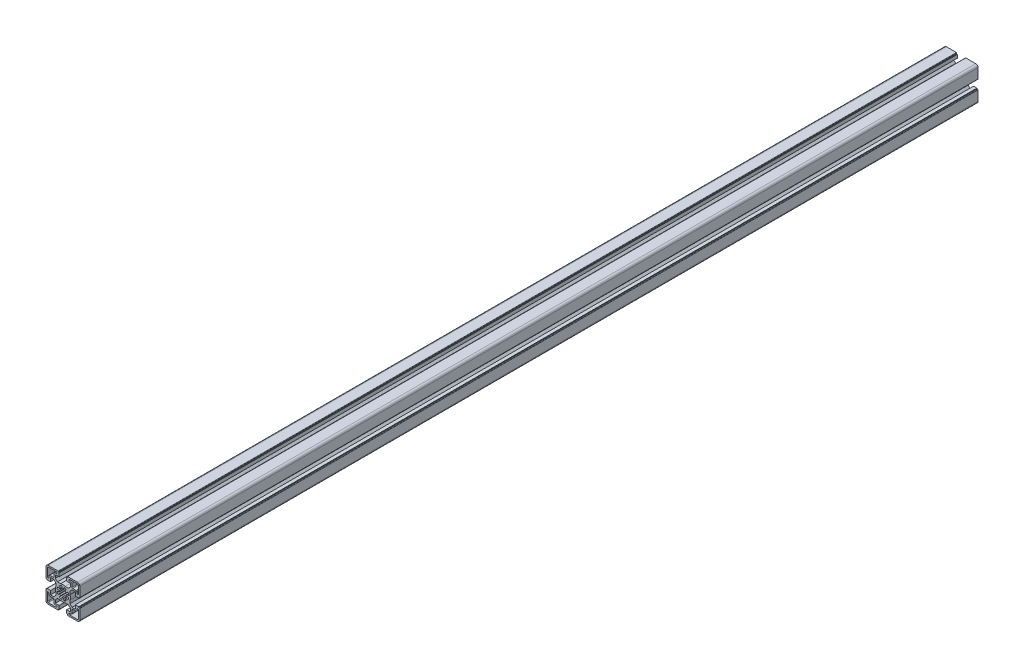
from build123d import *

# Parameters (mm, degrees)
BASE_EXTRUDE_DEPTH = 1196


with BuildPart() as part:
    # Sketch1 → Base-Extrude (new body)
    with BuildSketch(Plane.XY):
        with BuildLine():
            Line((-4.99999574, -16.499883971), (-4.99999574, -20.99990968))
            Line((-4.99999574, -20.99990968), (-5.80004044, -20.99990968))
            Line((-5.80004044, -20.99990968), (-5.80004044, -21.999970054))
            ThreePointArc((-5.80004044, -21.999970054), (-5.946487232, -22.353523887), (-6.300041066, -22.49997068))
            Line((-6.300041066, -22.49997068), (-19.500014911, -22.49997068))
            ThreePointArc((-19.500014911, -22.49997068), (-21.62133367, -21.62129168), (-22.50001267, -19.499972921))
            Line((-22.50001267, -19.499972921), (-22.50001267, -6.299929564))
            ThreePointArc((-22.50001267, -6.299929564), (-22.353566213, -5.946376541), (-22.00001319, -5.799930084))
            Line((-22.00001319, -5.799930084), (-21.000012806, -5.799930084))
            Line((-21.000012806, -5.799930084), (-21.000012806, -4.999940084))
            Line((-21.000012806, -4.999940084), (-16.500012806, -4.999940084))
            Line((-16.500012806, -4.999940084), (-16.500012806, -10.049940084))
            Line((-16.500012806, -10.049940084), (-12.342923806, -10.049940084))
            Line((-12.342923806, -10.049940084), (-9.499953806, -7.206970084))
            Line((-9.499953806, -7.206970084), (-9.499953806, -3.122617084))
            ThreePointArc((-9.499953806, -3.122617084), (-10.000013376, 6.1916e-05), (-9.499953806, 3.122740916))
            Line((-9.499953806, 3.122740916), (-9.499953806, 7.206970084))
            Line((-9.499953806, 7.206970084), (-12.342923806, 10.049940084))
            Line((-12.342923806, 10.049940084), (-16.500012806, 10.049940084))
            Line((-16.500012806, 10.049940084), (-16.500012806, 4.999940084))
            Line((-16.500012806, 4.999940084), (-21.000012806, 4.999940084))
            Line((-21.000012806, 4.999940084), (-21.000012806, 5.799930084))
            Line((-21.000012806, 5.799930084), (-22.00001319, 5.799930084))
            ThreePointArc((-22.00001319, 5.799930084), (-22.353566213, 5.946376541), (-22.50001267, 6.299929564))
            Line((-22.50001267, 6.299929564), (-22.50001267, 19.499972921))
            ThreePointArc((-22.50001267, 19.499972921), (-21.62133367, 21.62129168), (-19.500014911, 22.49997068))
            Line((-19.500014911, 22.49997068), (-6.299954884, 22.49997068))
            ThreePointArc((-6.299954884, 22.49997068), (-5.946364566, 22.353508775), (-5.799902661, 21.999918456))
            Line((-5.799902661, 21.999918456), (-5.799902661, 20.999918083))
            Line((-5.799902661, 20.999918083), (-4.99999574, 20.999918083))
            Line((-4.99999574, 20.999918083), (-4.99999574, 16.499989166))
            Line((-4.99999574, 16.499989166), (-10.050086009, 16.499989166))
            Line((-10.050086009, 16.499989166), (-10.050086009, 12.342794971))
            Line((-10.050086009, 12.342794971), (-7.207151696, 9.499860659))
            Line((-7.207151696, 9.499860659), (-3.122798696, 9.499860659))
            ThreePointArc((-3.122798696, 9.499860659), (-0.000120196, 9.999920064), (3.122558304, 9.499860659))
            Line((3.122558304, 9.499860659), (7.206958901, 9.499860659))
            Line((7.206958901, 9.499860659), (10.049884116, 12.342787874))
            Line((10.049884116, 12.342787874), (10.049884116, 16.499989166))
            Line((10.049884116, 16.499989166), (4.99999574, 16.499989166))
            Line((4.99999574, 16.499989166), (4.99999574, 20.999963909))
            Line((4.99999574, 20.999963909), (5.799902661, 20.999963909))
            Line((5.799902661, 20.999963909), (5.799902661, 21.999918456))
            ThreePointArc((5.799902661, 21.999918456), (5.946364566, 22.353508775), (6.299954884, 22.49997068))
            Line((6.299954884, 22.49997068), (19.500081571, 22.49997068))
            ThreePointArc((19.500081571, 22.49997068), (21.62140033, 21.62129168), (22.50007933, 19.499972921))
            Line((22.50007933, 19.499972921), (22.50007933, 6.299877709))
            ThreePointArc((22.50007933, 6.299877709), (22.35363283, 5.946324583), (22.000079704, 5.799878083))
            Line((22.000079704, 5.799878083), (20.999995421, 5.799878083))
            Line((20.999995421, 5.799878083), (20.999995421, 4.999941084))
            Line((20.999995421, 4.999941084), (16.499983596, 4.999941084))
            Line((16.499983596, 4.999941084), (16.499983596, 10.049940084))
            Line((16.499983596, 10.049940084), (12.342894596, 10.049940084))
            Line((12.342894596, 10.049940084), (9.499922596, 7.206970084))
            Line((9.499922596, 7.206970084), (9.499922596, 3.122735916))
            ThreePointArc((9.499922596, 3.122735916), (9.999982165, 5.6916e-05), (9.499922596, -3.122622084))
            Line((9.499922596, -3.122622084), (9.499922596, -7.206970084))
            Line((9.499922596, -7.206970084), (12.342894596, -10.049940084))
            Line((12.342894596, -10.049940084), (16.499983596, -10.049940084))
            Line((16.499983596, -10.049940084), (16.499983596, -4.999941084))
            Line((16.499983596, -4.999941084), (20.999995421, -4.999941084))
            Line((20.999995421, -4.999941084), (20.999995421, -5.799878083))
            Line((20.999995421, -5.799878083), (22.000079704, -5.799878083))
            ThreePointArc((22.000079704, -5.799878083), (22.35363283, -5.946324583), (22.50007933, -6.299877709))
            Line((22.50007933, -6.299877709), (22.50007933, -19.499973421))
            ThreePointArc((22.50007933, -19.499973421), (21.621400476, -21.621291826), (19.500082071, -22.49997068))
            Line((19.500082071, -22.49997068), (6.300041066, -22.49997068))
            ThreePointArc((6.300041066, -22.49997068), (5.946487232, -22.353523887), (5.80004044, -21.999970054))
            Line((5.80004044, -21.999970054), (5.80004044, -20.99990968))
            Line((5.80004044, -20.99990968), (4.99999574, -20.99990968))
            Line((4.99999574, -20.99990968), (4.99999574, -16.499883971))
            Line((4.99999574, -16.499883971), (10.049884116, -16.499883971))
            Line((10.049884116, -16.499883971), (10.049884116, -12.342787874))
            Line((10.049884116, -12.342787874), (7.206933602, -9.49983536))
            Line((7.206933602, -9.49983536), (3.122579602, -9.49983536))
            ThreePointArc((3.122579602, -9.49983536), (-9.9398e-05, -9.99989493), (-3.122778398, -9.49983536))
            Line((-3.122778398, -9.49983536), (-7.207126398, -9.49983536))
            Line((-7.207126398, -9.49983536), (-10.050086009, -12.342794971))
            Line((-10.050086009, -12.342794971), (-10.050086009, -16.499883971))
            Line((-10.050086009, -16.499883971), (-4.99999574, -16.499883971))
        make_face()
        with BuildLine():
            Line((0.868239441, 4.924019626), (1.389186106, 7.878448412))
            ThreePointArc((1.389186106, 7.878448412), (3.061471579, 7.391020172), (4.588617704, 6.553195784))
            Line((4.588617704, 6.553195784), (2.867879873, 4.095738521))
            ThreePointArc((2.867879873, 4.095738521), (3.535523556, 3.535517244), (4.095743641, 2.867872561))
            Line((4.095743641, 2.867872561), (6.553203976, 4.588606005))
            ThreePointArc((6.553203976, 4.588606005), (7.391023332, 3.061463952), (7.878448799, 1.389183909))
            Line((7.878448799, 1.389183909), (4.924019868, 0.868238068))
            ThreePointArc((4.924019868, 0.868238068), (4.9999809, 7.81e-07), (4.924020139, -0.868236529))
            Line((4.924020139, -0.868236529), (7.878449234, -1.389181447))
            ThreePointArc((7.878449234, -1.389181447), (7.391025132, -3.061459606), (6.553207937, -4.588600349))
            Line((6.553207937, -4.588600349), (4.095746117, -2.867869026))
            ThreePointArc((4.095746117, -2.867869026), (3.535522832, -3.535517968), (2.86787466, -4.095742171))
            Line((2.86787466, -4.095742171), (4.588609364, -6.553201624))
            ThreePointArc((4.588609364, -6.553201624), (3.061466598, -7.391022236), (1.389185513, -7.878448517))
            Line((1.389185513, -7.878448517), (0.868239071, -4.924019691))
            ThreePointArc((0.868239071, -4.924019691), (8.15e-07, -4.9999809), (-0.868237465, -4.924019974))
            Line((-0.868237465, -4.924019974), (-1.389182943, -7.87844897))
            ThreePointArc((-1.389182943, -7.87844897), (-3.06146423, -7.391023216), (-4.588607303, -6.553203067))
            Line((-4.588607303, -6.553203067), (-2.867873372, -4.095743073))
            ThreePointArc((-2.867873372, -4.095743073), (-3.535520061, -3.535520739), (-4.095742523, -2.867874158))
            Line((-4.095742523, -2.867874158), (-6.553202186, -4.588608561))
            ThreePointArc((-6.553202186, -4.588608561), (-7.391024272, -3.061461681), (-7.878450195, -1.389175997))
            Line((-7.878450195, -1.389175997), (-4.92402074, -0.868233124))
            ThreePointArc((-4.92402074, -0.868233124), (-4.9999809, 1.729e-06), (-4.924020139, 0.868236529))
            Line((-4.924020139, 0.868236529), (-7.878449234, 1.389181447))
            ThreePointArc((-7.878449234, 1.389181447), (-7.391023494, 3.061463561), (-6.553203027, 4.588607361))
            Line((-6.553203027, 4.588607361), (-4.095743048, 2.867873408))
            ThreePointArc((-4.095743048, 2.867873408), (-3.535525782, 3.535515019), (-2.867885877, 4.095734317))
            Line((-2.867885877, 4.095734317), (-4.588627311, 6.553189058))
            ThreePointArc((-4.588627311, 6.553189058), (-3.061465289, 7.391022778), (-1.389161147, 7.878452813))
            Line((-1.389161147, 7.878452813), (-0.868223842, 4.924022376))
            ThreePointArc((-0.868223842, 4.924022376), (7.92e-06, 4.9999809), (0.868239441, 4.924019626))
        make_face(mode=Mode.SUBTRACT)
        with BuildLine():
            Line((-17.500118733, -12.000017917), (-13.000117238, -12.000017917))
            ThreePointArc((-13.000117238, -12.000017917), (-12.293010985, -12.292910917), (-12.000117985, -13.00001717))
            Line((-12.000117985, -13.00001717), (-12.000117985, -17.49992083))
            ThreePointArc((-12.000117985, -17.49992083), (-11.707224985, -18.207027083), (-11.000118733, -18.499920083))
            Line((-11.000118733, -18.499920083), (-9.000117985, -18.499920083))
            ThreePointArc((-9.000117985, -18.499920083), (-8.000069068, -19.499969), (-9.000117985, -20.500017917))
            Line((-9.000117985, -20.500017917), (-19.500118733, -20.500017917))
            ThreePointArc((-19.500118733, -20.500017917), (-20.207224985, -20.207124917), (-20.500117985, -19.500018664))
            Line((-20.500117985, -19.500018664), (-20.500117985, -8.999920083))
            ThreePointArc((-20.500117985, -8.999920083), (-19.500117985, -7.999920083), (-18.500117985, -8.999920083))
            Line((-18.500117985, -8.999920083), (-18.500117985, -11.000018664))
            ThreePointArc((-18.500117985, -11.000018664), (-18.207224985, -11.707124917), (-17.500118733, -12.000017917))
        make_face(mode=Mode.SUBTRACT)
        with BuildLine():
            Line((13.000003267, -12.000017917), (17.500004762, -12.000017917))
            ThreePointArc((17.500004762, -12.000017917), (18.207111015, -11.707124917), (18.500004015, -11.000018664))
            Line((18.500004015, -11.000018664), (18.500004015, -9.000115751))
            ThreePointArc((18.500004015, -9.000115751), (19.500004015, -8.000115751), (20.500004015, -9.000115751))
            Line((20.500004015, -9.000115751), (20.500004015, -19.500018664))
            ThreePointArc((20.500004015, -19.500018664), (20.207111015, -20.207124917), (19.500004762, -20.500017917))
            Line((19.500004762, -20.500017917), (9.000004015, -20.500017917))
            ThreePointArc((9.000004015, -20.500017917), (7.999955097, -19.499969), (9.000004015, -18.499920083))
            Line((9.000004015, -18.499920083), (11.000004762, -18.499920083))
            ThreePointArc((11.000004762, -18.499920083), (11.707111015, -18.207027083), (12.000004015, -17.49992083))
            Line((12.000004015, -17.49992083), (12.000004015, -13.00001717))
            ThreePointArc((12.000004015, -13.00001717), (12.292897015, -12.292910917), (13.000003267, -12.000017917))
        make_face(mode=Mode.SUBTRACT)
        with BuildLine():
            Line((-17.500118733, 12.000017917), (-13.000117238, 12.000017917))
            ThreePointArc((-13.000117238, 12.000017917), (-12.293010985, 12.292910917), (-12.000117985, 13.00001717))
            Line((-12.000117985, 13.00001717), (-12.000117985, 17.49992083))
            ThreePointArc((-12.000117985, 17.49992083), (-11.707224985, 18.207027083), (-11.000118733, 18.499920083))
            Line((-11.000118733, 18.499920083), (-9.000117985, 18.499920083))
            ThreePointArc((-9.000117985, 18.499920083), (-8.000069068, 19.499969), (-9.000117985, 20.500017917))
            Line((-9.000117985, 20.500017917), (-19.500118733, 20.500017917))
            ThreePointArc((-19.500118733, 20.500017917), (-20.207224985, 20.207124917), (-20.500117985, 19.500018664))
            Line((-20.500117985, 19.500018664), (-20.500117985, 8.999920083))
            ThreePointArc((-20.500117985, 8.999920083), (-19.500117985, 7.999920083), (-18.500117985, 8.999920083))
            Line((-18.500117985, 8.999920083), (-18.500117985, 11.000018664))
            ThreePointArc((-18.500117985, 11.000018664), (-18.207224985, 11.707124917), (-17.500118733, 12.000017917))
        make_face(mode=Mode.SUBTRACT)
        with BuildLine():
            Line((13.000003267, 12.000017917), (17.500004762, 12.000017917))
            ThreePointArc((17.500004762, 12.000017917), (18.207111015, 11.707124917), (18.500004015, 11.000018664))
            Line((18.500004015, 11.000018664), (18.500004015, 9.000115751))
            ThreePointArc((18.500004015, 9.000115751), (19.500004015, 8.000115751), (20.500004015, 9.000115751))
            Line((20.500004015, 9.000115751), (20.500004015, 19.500018664))
            ThreePointArc((20.500004015, 19.500018664), (20.207111015, 20.207124917), (19.500004762, 20.500017917))
            Line((19.500004762, 20.500017917), (9.000004015, 20.500017917))
            ThreePointArc((9.000004015, 20.500017917), (7.999955097, 19.499969), (9.000004015, 18.499920083))
            Line((9.000004015, 18.499920083), (11.000004762, 18.499920083))
            ThreePointArc((11.000004762, 18.499920083), (11.707111015, 18.207027083), (12.000004015, 17.49992083))
            Line((12.000004015, 17.49992083), (12.000004015, 13.00001717))
            ThreePointArc((12.000004015, 13.00001717), (12.292897015, 12.292910917), (13.000003267, 12.000017917))
        make_face(mode=Mode.SUBTRACT)
    extrude(amount=BASE_EXTRUDE_DEPTH)


solid = part.part
